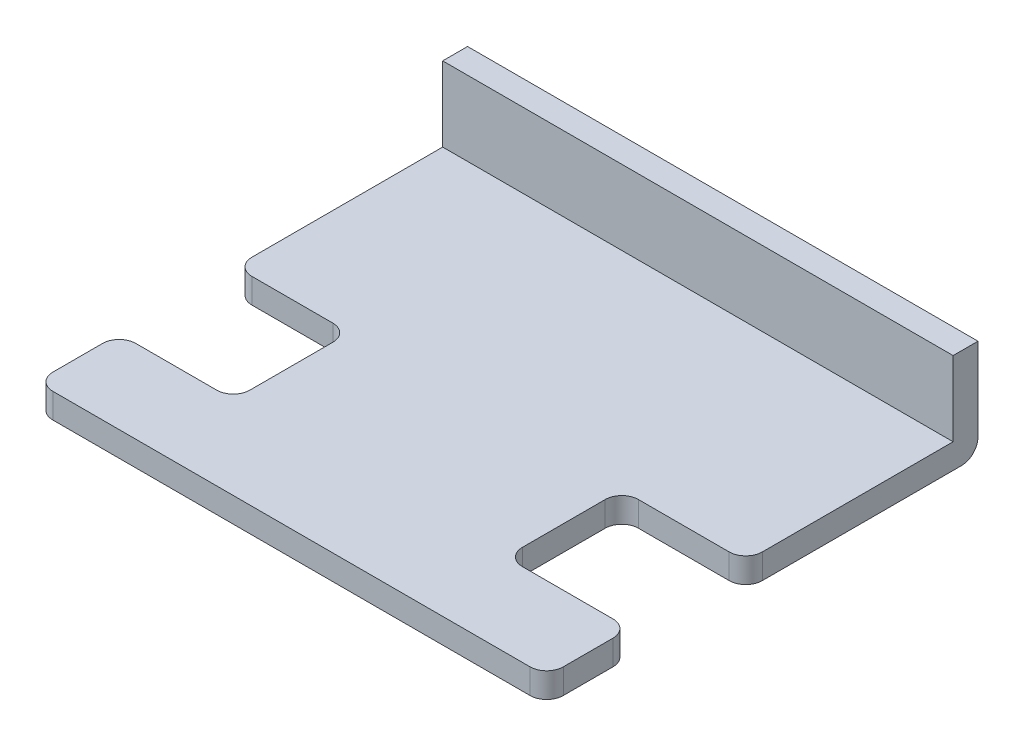
from build123d import *

# Parameters (mm, degrees)
BOSS_EXTRUDE1_DEPTH = 3
SKETCH2_W           = 61.538461538
SKETCH2_H           = 12
BOSS_EXTRUDE2_DEPTH = 3
FILLET1_R           = 2


with BuildPart() as part:
    # Sketch1 → Boss-Extrude1 (new body)
    with BuildSketch(Plane(origin=(0, 0, 0), x_dir=(1, 0, 0), z_dir=(0, 1, 0))):
        with BuildLine():
            Line((18.124260355, -19.786982249), (29.065088757, -19.786982249))
            ThreePointArc((29.065088757, -19.786982249), (30.47930232, -19.201195811), (31.065088757, -17.786982249))
            Line((31.065088757, -17.786982249), (31.065088757, 5.213017751))
            Line((31.065088757, 5.213017751), (-30.473372781, 5.213017751))
            Line((-30.473372781, 5.213017751), (-30.473372781, -17.786982249))
            ThreePointArc((-30.473372781, -17.786982249), (-29.887586343, -19.201195811), (-28.473372781, -19.786982249))
            Line((-28.473372781, -19.786982249), (-18.715976331, -19.786982249))
            ThreePointArc((-18.715976331, -19.786982249), (-17.301762769, -20.372768686), (-16.715976331, -21.786982249))
            Line((-16.715976331, -21.786982249), (-16.715976331, -31.786982249))
            ThreePointArc((-16.715976331, -31.786982249), (-17.301762769, -33.201195811), (-18.715976331, -33.786982249))
            Line((-18.715976331, -33.786982249), (-28.473372781, -33.786982249))
            ThreePointArc((-28.473372781, -33.786982249), (-29.887586343, -34.372768686), (-30.473372781, -35.786982249))
            Line((-30.473372781, -35.786982249), (-30.473372781, -41.786982249))
            ThreePointArc((-30.473372781, -41.786982249), (-29.887586343, -43.201195811), (-28.473372781, -43.786982249))
            Line((-28.473372781, -43.786982249), (29.065088757, -43.786982249))
            ThreePointArc((29.065088757, -43.786982249), (30.47930232, -43.201195811), (31.065088757, -41.786982249))
            Line((31.065088757, -41.786982249), (31.065088757, -35.786982249))
            ThreePointArc((31.065088757, -35.786982249), (30.47930232, -34.372768686), (29.065088757, -33.786982249))
            Line((29.065088757, -33.786982249), (18.124260355, -33.786982249))
            ThreePointArc((18.124260355, -33.786982249), (16.710046793, -33.201195811), (16.124260355, -31.786982249))
            Line((16.124260355, -31.786982249), (16.124260355, -21.786982249))
            ThreePointArc((16.124260355, -21.786982249), (16.710046793, -20.372768686), (18.124260355, -19.786982249))
        make_face()
    extrude(amount=BOSS_EXTRUDE1_DEPTH)

    # Sketch2 → Boss-Extrude2 (add)
    with BuildSketch(Plane(origin=(0, 0, -5.213017751), x_dir=(-1, 0, 0), z_dir=(0, 0, -1))):
        with Locations((-0.295857988, 6)):
            Rectangle(SKETCH2_W, SKETCH2_H)
    extrude(amount=BOSS_EXTRUDE2_DEPTH)

    # Fillet1
    fillet1_edges = [part.edges().sort_by_distance(p)[0] for p in [
        (0.295857988, 0, -8.213017751),
    ]]
    fillet(fillet1_edges, radius=FILLET1_R)


solid = part.part
